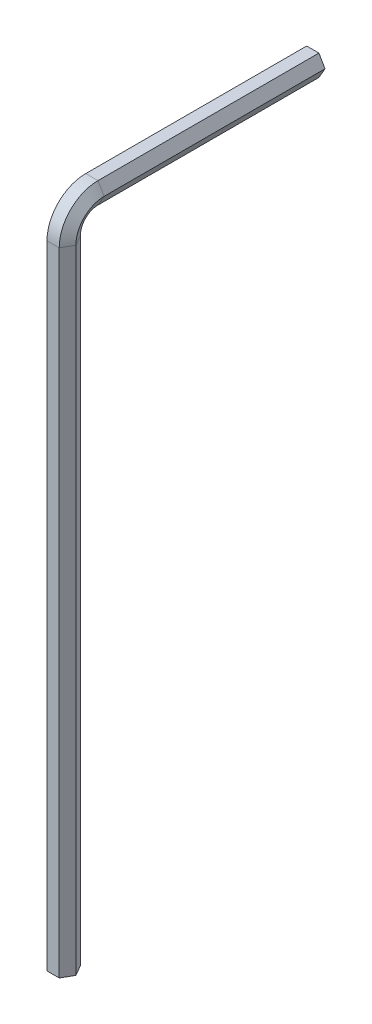
from build123d import *


with BuildPart() as part:
    # Sweep1: sweep along a path in Sketch2
    with BuildLine(Plane.ZY) as sweep1_path:
        Line((0, 0), (0, 44.8))
        ThreePointArc((0, 44.8), (-0.585786438, 46.214213562), (-2, 46.8))
        Line((-2, 46.8), (-17.65, 46.8))
    # Sketch1 → Sweep1 (sweep)
    with BuildSketch(Plane(origin=(0, 0, 0), x_dir=(1, 0, 0), z_dir=(0, 1, 0))):
        Polygon((0.866025404, 0), (0.433012702, 0.75), (-0.433012702, 0.75), (-0.866025404, 0), (-0.433012702, -0.75), (0.433012702, -0.75), align=None)
    sweep(path=sweep1_path.line)


solid = part.part
